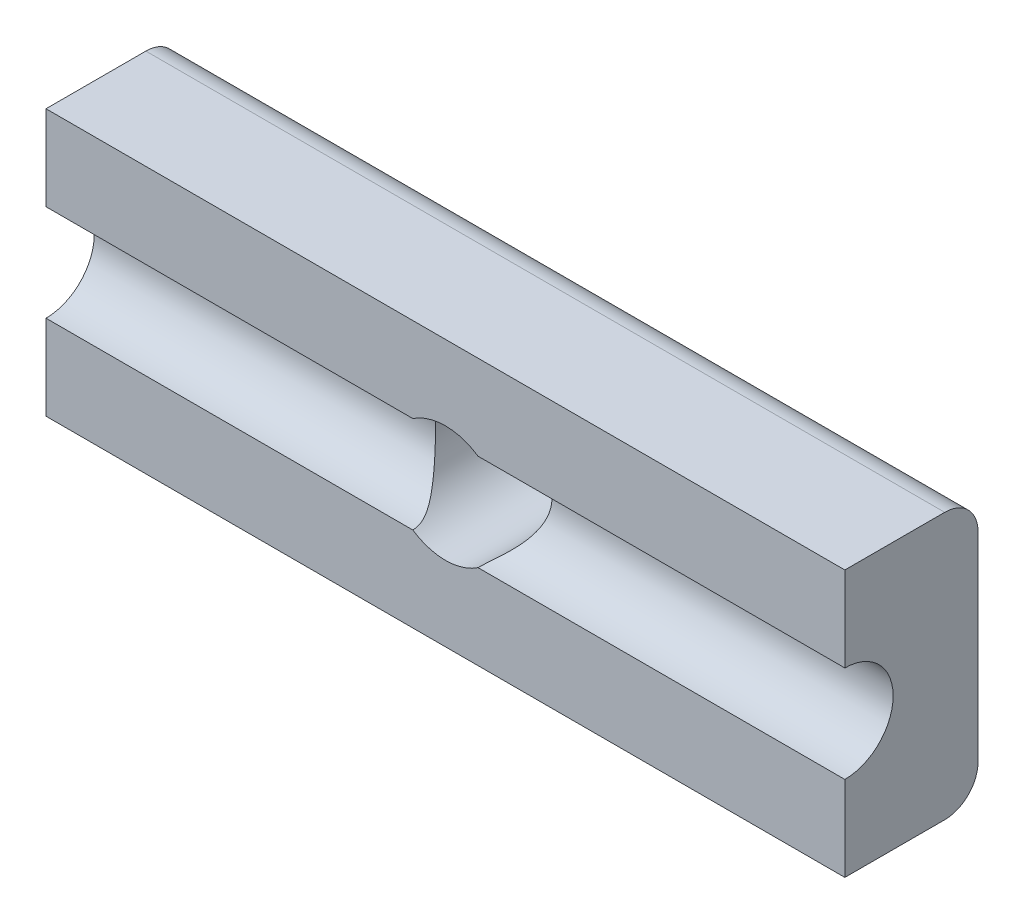
from build123d import *

# Parameters (mm, degrees)
SKETCH2_W           = 24
SKETCH2_H           = 8
BOSS_EXTRUDE1_DEPTH = 4
SKETCH3_R           = 1.75
CUT_EXTRUDE1_DEPTH  = 5
SKETCH4_R           = 1.45
CUT_EXTRUDE2_DEPTH  = 44
FILLET1_R           = 1


with BuildPart() as part:
    # Sketch2 → Boss-Extrude1 (new body)
    with BuildSketch(Plane.XY):
        with Locations((6.957345972, 0)):
            Rectangle(SKETCH2_W, SKETCH2_H)
    extrude(amount=BOSS_EXTRUDE1_DEPTH)

    # Sketch3 → Cut-Extrude1 (cut)
    with BuildSketch(Plane.XY.offset(4)):
        with Locations((6.957345972, 0)):
            Circle(SKETCH3_R)
    extrude(amount=-CUT_EXTRUDE1_DEPTH, mode=Mode.SUBTRACT)

    # Sketch4 → Cut-Extrude2 (cut)
    with BuildSketch(Plane.ZY.offset(5.042654028)):
        with Locations((4, 0)):
            Circle(SKETCH4_R)
    extrude(amount=-CUT_EXTRUDE2_DEPTH, mode=Mode.SUBTRACT)

    # Fillet1
    fillet1_edges = [part.edges().sort_by_distance(p)[0] for p in [
        (6.957345972, 4, 0),
        (6.957345972, -4, 0),
    ]]
    fillet(fillet1_edges, radius=FILLET1_R)


solid = part.part
